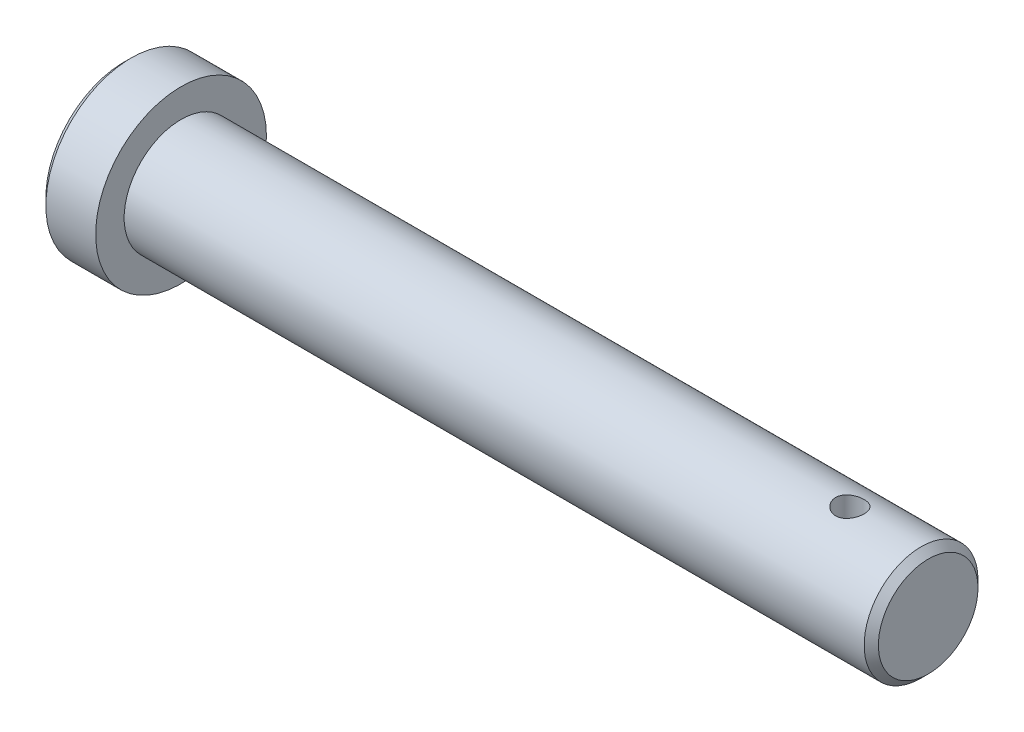
from build123d import *

# Parameters (mm, degrees)
SKETCH1_R           = 12
BOSS_EXTRUDE1_DEPTH = 8
CHAMFER1_SIZE       = 1
SKETCH2_R           = 8
BOSS_EXTRUDE2_DEPTH = 105
CHAMFER2_SIZE       = 1
SKETCH3_R           = 2
CUT_EXTRUDE1_DEPTH  = 52.5


with BuildPart() as part:
    # Sketch1 → Boss-Extrude1 (new body)
    with BuildSketch(Plane(origin=(0, 0, 0), x_dir=(0, 0, -1), z_dir=(1, 0, 0))):
        Circle(SKETCH1_R)
    extrude(amount=BOSS_EXTRUDE1_DEPTH)

    # Chamfer1
    chamfer1_edges = [part.edges().sort_by_distance(p)[0] for p in [
        (0, 0, 12),
    ]]
    chamfer(chamfer1_edges, length=CHAMFER1_SIZE)

    # Sketch2 → Boss-Extrude2 (add)
    with BuildSketch(Plane(origin=(8, 0, 0), x_dir=(0, 0, -1), z_dir=(1, 0, 0))):
        Circle(SKETCH2_R)
    extrude(amount=BOSS_EXTRUDE2_DEPTH)

    # Chamfer2
    chamfer2_edges = [part.edges().sort_by_distance(p)[0] for p in [
        (113, 0, 8),
    ]]
    chamfer(chamfer2_edges, length=CHAMFER2_SIZE)

    # Sketch3 → Cut-Extrude1 (cut, symmetric)
    with BuildSketch(Plane(origin=(0, 0, 0), x_dir=(1, 0, 0), z_dir=(0, 1, 0))):
        with Locations((102, 0)):
            Circle(SKETCH3_R)
    extrude(amount=CUT_EXTRUDE1_DEPTH, both=True, mode=Mode.SUBTRACT)


solid = part.part
